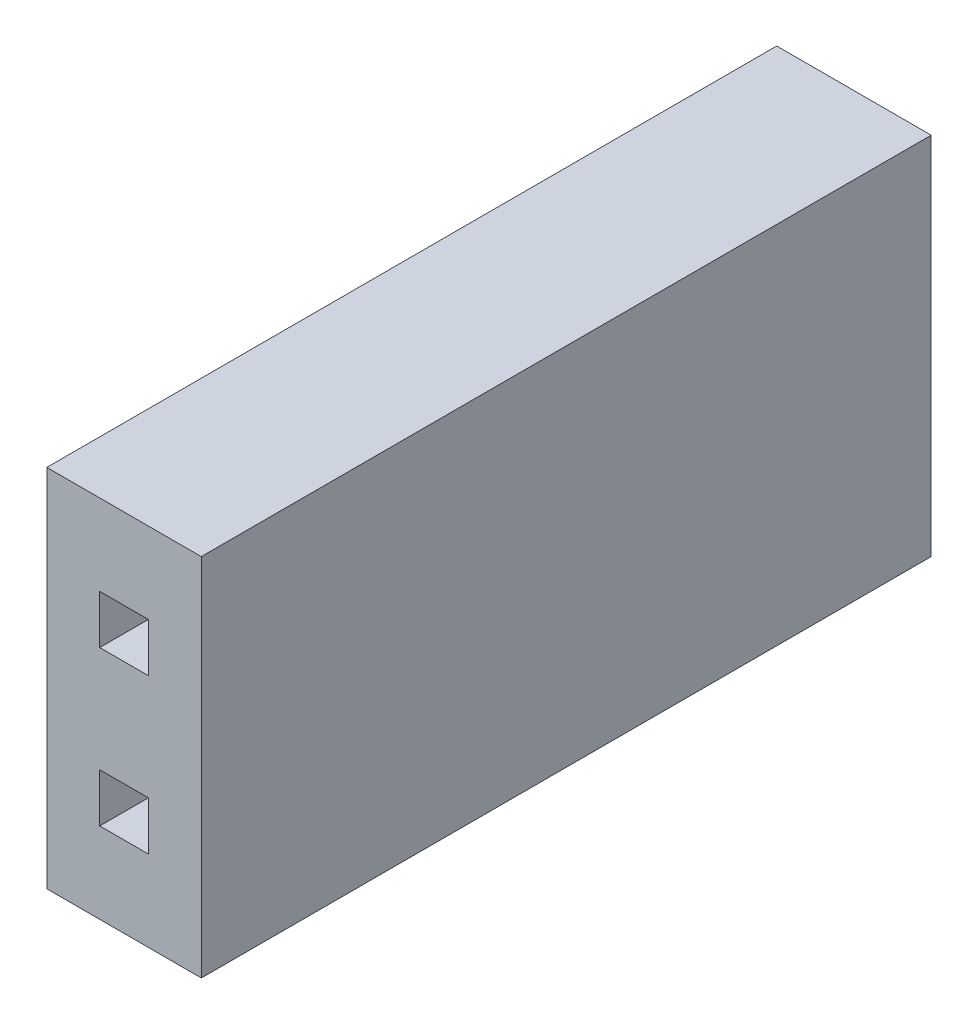
from build123d import *

# Parameters (mm, degrees)
SKETCH_1_W          = 2.54
SKETCH_1_H          = 6
EXTRUDE_1_DEPTH     = 12
SKETCH_2_W          = 2
SKETCH_2_H          = 2
CUT_EXTRUDE_1_DEPTH = 4
SKETCH_3_R          = 0.65
EXTRUDE_2_DEPTH     = 4
SKETCH_4_W          = 0.8
SKETCH_4_H          = 0.8
CUT_EXTRUDE_2_DEPTH = 5


with BuildPart() as part:
    # Эскиз1 → Бобышка-Вытянуть1 (new body)
    with BuildSketch(Plane.XY):
        with Locations((1.27, 3)):
            Rectangle(SKETCH_1_W, SKETCH_1_H)
    extrude(amount=EXTRUDE_1_DEPTH)

    # Эскиз2 → Вырез-Вытянуть1 (cut)
    with BuildSketch(Plane(origin=(0, 0, 0), x_dir=(-1, 0, 0), z_dir=(0, 0, -1))):
        with Locations((-1.27, 4.27)):
            Rectangle(SKETCH_2_W, SKETCH_2_H)
        with Locations((-1.27, 1.73)):
            Rectangle(SKETCH_2_W, SKETCH_2_H)
    extrude(amount=-CUT_EXTRUDE_1_DEPTH, mode=Mode.SUBTRACT)

    # Эскиз3 → Бобышка-Вытянуть2 (add)
    with BuildSketch(Plane(origin=(0, 0, 4), x_dir=(-1, 0, 0), z_dir=(0, 0, -1))):
        with Locations((-1.27, 4.27)):
            Circle(SKETCH_3_R)
        with Locations((-1.27, 1.73)):
            Circle(SKETCH_3_R)
    extrude(amount=EXTRUDE_2_DEPTH)

    # Эскиз4 → Вырез-Вытянуть2 (cut)
    with BuildSketch(Plane.XY.offset(12)):
        with Locations((1.27, 4.27)):
            Rectangle(SKETCH_4_W, SKETCH_4_H)
        with Locations((1.27, 1.73)):
            Rectangle(SKETCH_4_W, SKETCH_4_H)
    extrude(amount=-CUT_EXTRUDE_2_DEPTH, mode=Mode.SUBTRACT)


solid = part.part
